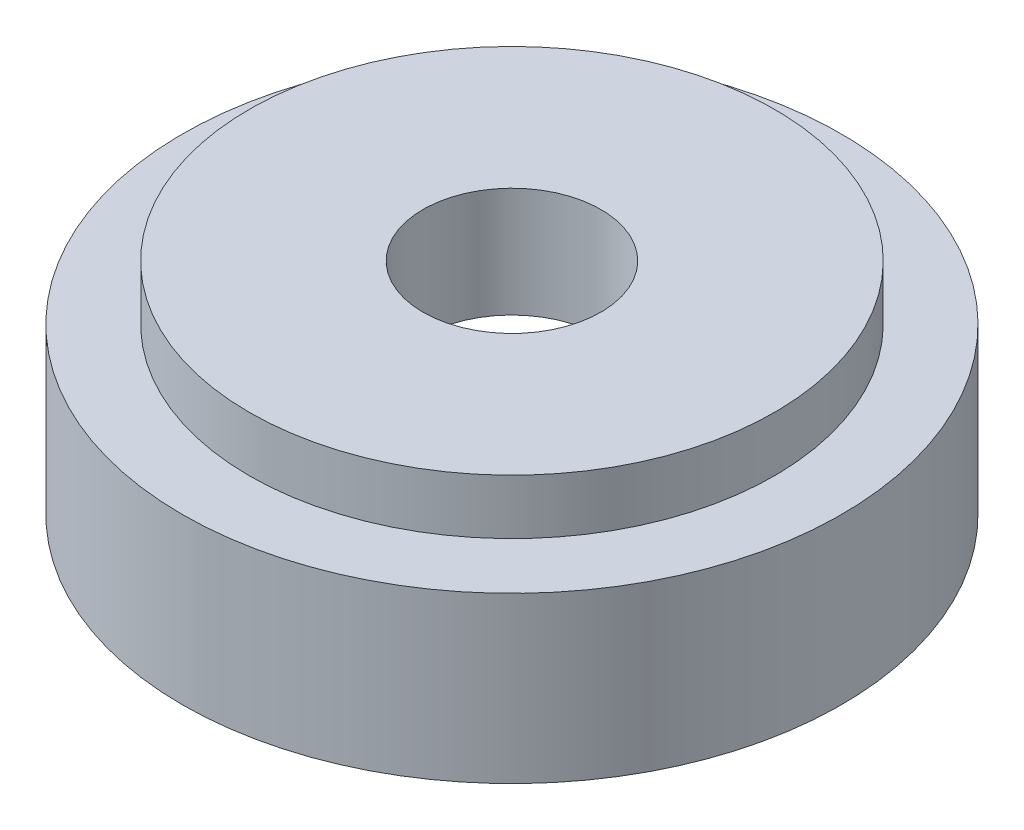
from build123d import *

# Parameters (mm, degrees)
CROQUIS1_R              = 23.9
CROQUIS1_R_2            = 8.1
SALIENTE_EXTRUIR1_DEPTH = 5
SALIENTE_EXTRUIR2_START = -5
CROQUIS1_3_R            = 30
CROQUIS1_3_R_2          = 8.1
SALIENTE_EXTRUIR2_DEPTH = 5
SALIENTE_EXTRUIR3_START = -15
CROQUIS1_4_R            = 30
CROQUIS1_4_R_2          = 23.9
SALIENTE_EXTRUIR3_DEPTH = 15


with BuildPart() as part:
    # Croquis1 → Saliente-Extruir1 (new body)
    with BuildSketch(Plane(origin=(0, 0, 0), x_dir=(1, 0, 0), z_dir=(0, 1, 0))):
        Circle(CROQUIS1_R)
        Circle(CROQUIS1_R_2, mode=Mode.SUBTRACT)
    extrude(amount=SALIENTE_EXTRUIR1_DEPTH)

    # Croquis1_3 → Saliente-Extruir2 (add)
    with BuildSketch(Plane(origin=(0, 0, 0), x_dir=(1, 0, 0), z_dir=(0, 1, 0)).offset(SALIENTE_EXTRUIR2_START)):
        Circle(CROQUIS1_3_R)
        Circle(CROQUIS1_3_R_2, mode=Mode.SUBTRACT)
    extrude(amount=SALIENTE_EXTRUIR2_DEPTH)

    # Croquis1_4 → Saliente-Extruir3 (add)
    with BuildSketch(Plane(origin=(0, 0, 0), x_dir=(1, 0, 0), z_dir=(0, 1, 0)).offset(SALIENTE_EXTRUIR3_START)):
        Circle(CROQUIS1_4_R)
        Circle(CROQUIS1_4_R_2, mode=Mode.SUBTRACT)
    extrude(amount=SALIENTE_EXTRUIR3_DEPTH)


solid = part.part
